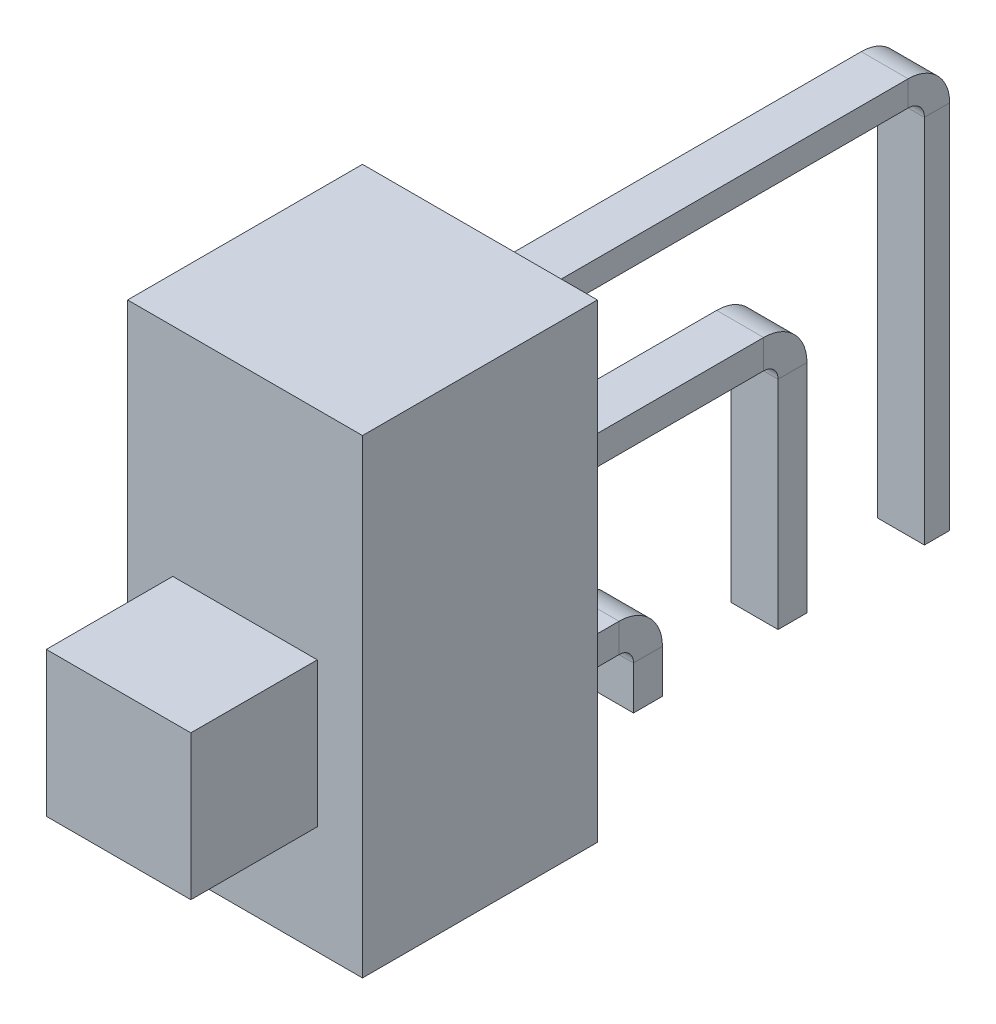
from build123d import *

# Parameters (mm, degrees)
SKICA1_W                = 6.5
SKICA1_H                = 6.5
P_IDAT_VYSUNUT_M1_DEPTH = 13
SKICA2_W                = 4
SKICA2_H                = 4
P_IDAT_VYSUNUT_M2_DEPTH = 3.5
SKICA3_W                = 1.3
SKICA3_H                = 0.7
SKICA5_W                = 1.3
SKICA5_H                = 0.8
SKICA7_W                = 1.3
SKICA7_H                = 0.8


with BuildPart() as part:
    # Skica1 → Přidat vysunutím1 (new body)
    with BuildSketch(Plane(origin=(0, 0, 0), x_dir=(1, 0, 0), z_dir=(0, 1, 0))):
        Rectangle(SKICA1_W, SKICA1_H)
    extrude(amount=P_IDAT_VYSUNUT_M1_DEPTH)

    # Skica2 → Přidat vysunutím2 (add)
    with BuildSketch(Plane.XY.offset(3.25)):
        with Locations((0, 5)):
            Rectangle(SKICA2_W, SKICA2_H)
    extrude(amount=P_IDAT_VYSUNUT_M2_DEPTH)

    # Táhnout po křivce1: sweep along a path in Skica4
    with BuildLine(Plane(origin=(0, 0, 0), x_dir=(0, 0, -1), z_dir=(1, 0, 0))) as t_hnout_po_k_ivce1_path:
        Line((3.25, 11.05), (14.45, 11.05))
        ThreePointArc((14.45, 11.05), (15.015685425, 10.815685425), (15.25, 10.25))
        Line((15.25, 10.25), (15.25, 0))
    # Skica3 → Táhnout po křivce1 (sweep)
    with BuildSketch(Plane(origin=(0, 0, -3.25), x_dir=(-1, 0, 0), z_dir=(0, 0, -1))):
        with Locations((0, 11.05)):
            Rectangle(SKICA3_W, SKICA3_H)
    sweep(path=t_hnout_po_k_ivce1_path.line)

    # Táhnout po křivce2: sweep along a path in Skica6
    with BuildLine(Plane(origin=(0, 0, 0), x_dir=(0, 0, -1), z_dir=(1, 0, 0))) as t_hnout_po_k_ivce2_path:
        Line((3.25, 6.8), (10.45, 6.8))
        ThreePointArc((10.45, 6.8), (11.015685425, 6.565685425), (11.25, 6))
        Line((11.25, 6), (11.25, 0))
    # Skica5 → Táhnout po křivce2 (sweep)
    with BuildSketch(Plane(origin=(0, 0, -3.25), x_dir=(-1, 0, 0), z_dir=(0, 0, -1))):
        with Locations((0, 6.8)):
            Rectangle(SKICA5_W, SKICA5_H)
    sweep(path=t_hnout_po_k_ivce2_path.line)

    # Táhnout po křivce3: sweep along a path in Skica8
    with BuildLine(Plane(origin=(0, 0, 0), x_dir=(0, 0, -1), z_dir=(1, 0, 0))) as t_hnout_po_k_ivce3_path:
        Line((3.25, 2), (6.45, 2))
        ThreePointArc((6.45, 2), (7.015685425, 1.765685425), (7.25, 1.2))
        Line((7.25, 1.2), (7.25, 0))
    # Skica7 → Táhnout po křivce3 (sweep)
    with BuildSketch(Plane(origin=(0, 0, -3.25), x_dir=(-1, 0, 0), z_dir=(0, 0, -1))):
        with Locations((0, 2)):
            Rectangle(SKICA7_W, SKICA7_H)
    sweep(path=t_hnout_po_k_ivce3_path.line)


solid = part.part
